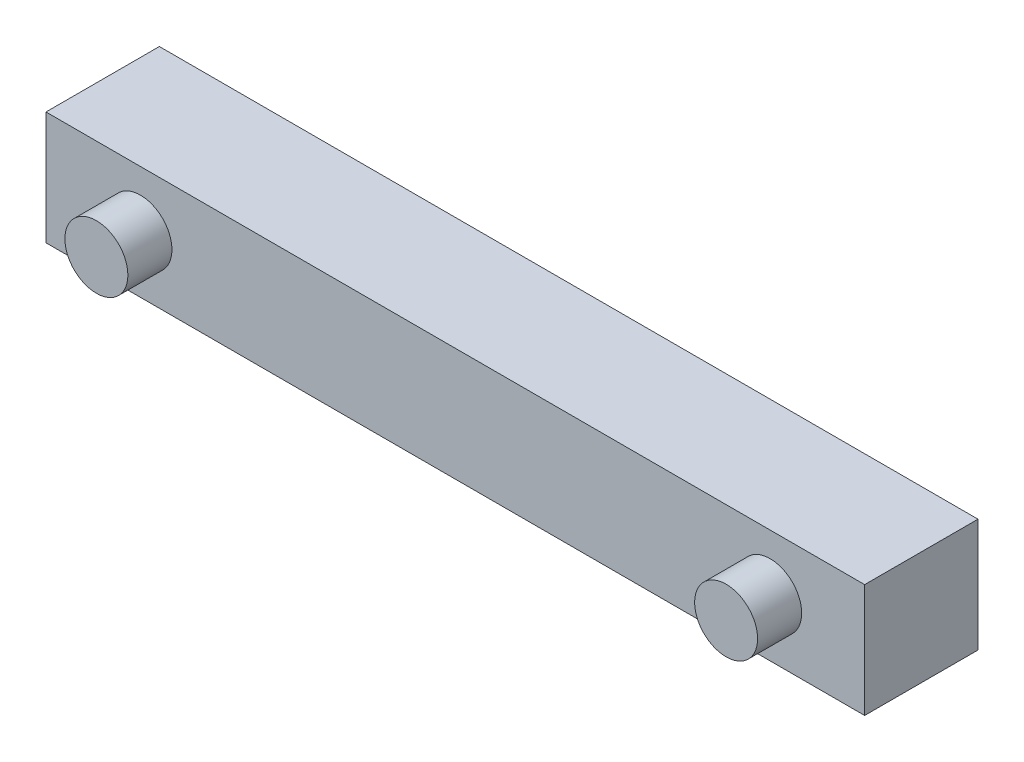
from build123d import *

# Parameters (mm, degrees)
SKETCH1_W           = 65
SKETCH1_H           = 9
BOSS_EXTRUDE1_DEPTH = 9
SKETCH2_R           = 2.5
BOSS_EXTRUDE2_DEPTH = 3.5


with BuildPart() as part:
    # Sketch1 → Boss-Extrude1 (new body)
    with BuildSketch(Plane.XY):
        with Locations((32.5, 4.5)):
            Rectangle(SKETCH1_W, SKETCH1_H)
    extrude(amount=BOSS_EXTRUDE1_DEPTH)

    # Sketch2 → Boss-Extrude2 (add)
    with BuildSketch(Plane.XY.offset(9)):
        with Locations(Location((7.5, 4.530142984, 0), (0, 0, 180))):  # turned: the seam where the file's is
            Circle(SKETCH2_R)
        with Locations(Location((57.5, 4.530142984, 0), (0, 0, 180))):  # turned: the seam where the file's is
            Circle(SKETCH2_R)
    extrude(amount=BOSS_EXTRUDE2_DEPTH)


solid = part.part
